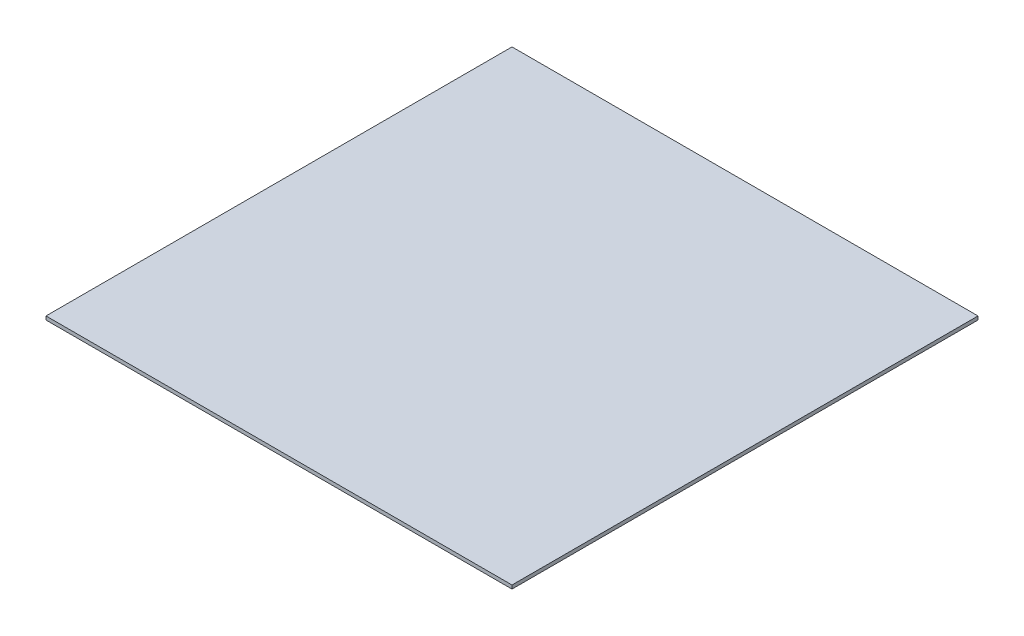
from build123d import *

# Parameters (mm, degrees)
SKETCH1_W           = 130
SKETCH1_H           = 130
BOSS_EXTRUDE1_DEPTH = 1


with BuildPart() as part:
    # Sketch1 → Boss-Extrude1 (new body)
    with BuildSketch(Plane(origin=(0, 0, 0), x_dir=(1, 0, 0), z_dir=(0, 1, 0))):
        with Locations((17.968311827, 16.899409823)):
            Rectangle(SKETCH1_W, SKETCH1_H)
    extrude(amount=BOSS_EXTRUDE1_DEPTH)


solid = part.part
